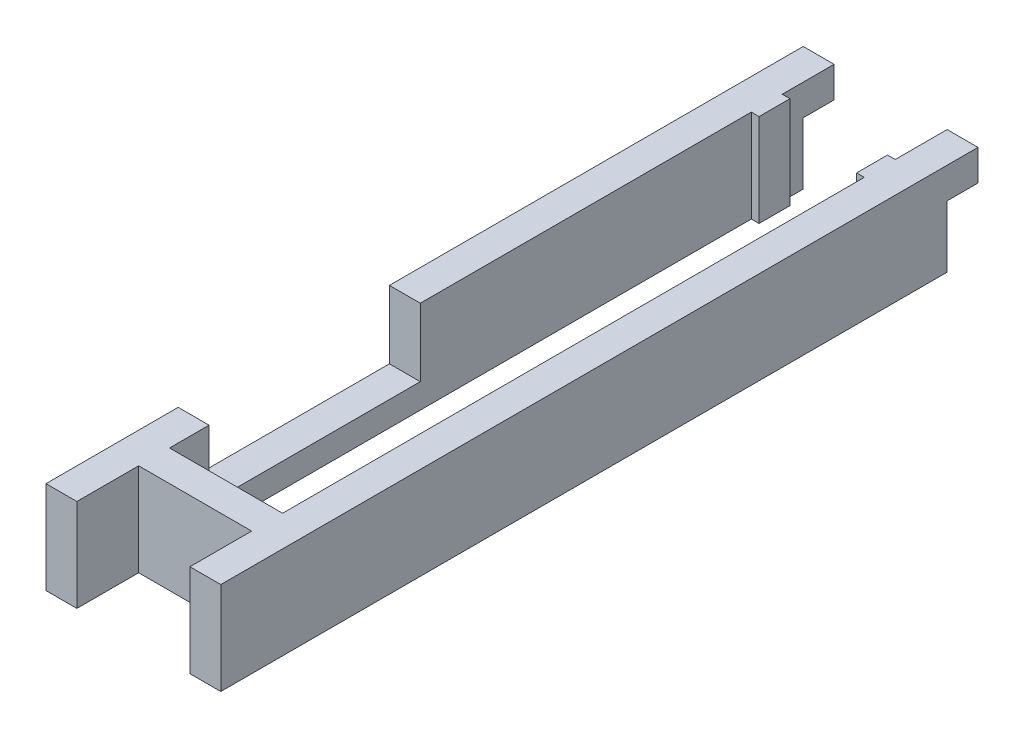
from build123d import *

# Parameters (mm, degrees)
BOSS_EXTRUDE1_DEPTH = 19.05
SKETCH2_W           = 43.434
SKETCH2_H           = 13.97
MOTOR_HOLE_DEPTH    = 19.05
SKETCH3_W           = 6.35
SKETCH3_H           = 12.7
CUT_EXTRUDE2_DEPTH  = 36.941


with BuildPart() as part:
    # Sketch1 → Boss-Extrude1 (new body)
    with BuildSketch(Plane(origin=(0, 0, 0), x_dir=(1, 0, 0), z_dir=(0, 1, 0))):
        Polygon((-10.033, 66.167), (-11.6205, 66.167), (-11.6205, 76.835), (-17.9705, 76.835), (-17.9705, -78.867), (-11.6205, -78.867), (-11.6205, -66.167), (11.6205, -66.167), (11.6205, -78.867), (17.9705, -78.867), (17.9705, 76.835), (11.6205, 76.835), (11.6205, 66.167), (10.033, 66.167), (10.033, 59.817), (11.6205, 59.817), (11.6205, -59.817), (-11.6205, -59.817), (-11.6205, 59.817), (-10.033, 59.817), align=None)
    extrude(amount=BOSS_EXTRUDE1_DEPTH)

    # Sketch2 → Motor Hole (cut)
    with BuildSketch(Plane.ZY.offset(17.9705)):
        with Locations((29.972, 12.065)):
            Rectangle(SKETCH2_W, SKETCH2_H)
    extrude(amount=-MOTOR_HOLE_DEPTH, mode=Mode.SUBTRACT)

    # Sketch3 → Cut-Extrude2 (cut, through all)
    with BuildSketch(Plane.ZY.offset(17.9705)):
        with Locations((-73.66, 6.35)):
            Rectangle(SKETCH3_W, SKETCH3_H)
    extrude(amount=-CUT_EXTRUDE2_DEPTH, mode=Mode.SUBTRACT)


solid = part.part
